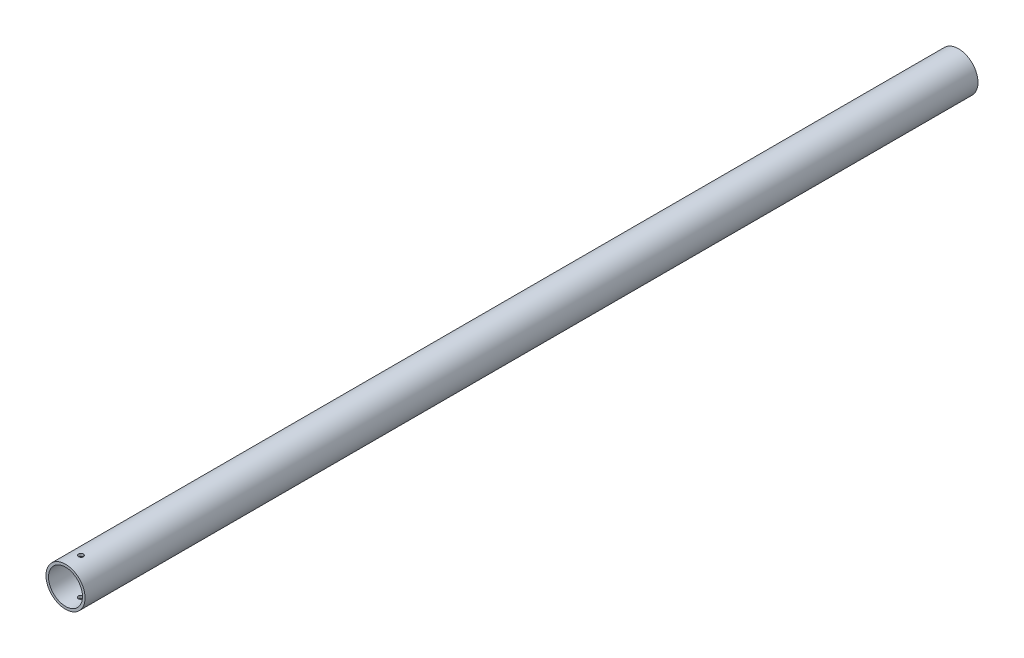
from build123d import *

# Parameters (mm, degrees)
SKETCH1_R               = 12.7
SKETCH1_R_2             = 11.049
BOSS_EXTRUDE1_DEPTH     = 580
SKETCH2_R               = 1.6
CUT_EXTRUDE1_DEPTH      = 13.7
CUT_EXTRUDE1_DEPTH_BACK = 13.7


with BuildPart() as part:
    # Sketch1 → Boss-Extrude1 (new body)
    with BuildSketch(Plane.XY):
        Circle(SKETCH1_R)
        Circle(SKETCH1_R_2, mode=Mode.SUBTRACT)
    extrude(amount=BOSS_EXTRUDE1_DEPTH)

    # Sketch2 → Cut-Extrude1 (cut, two sides)
    with BuildSketch(Plane(origin=(0, 0, 0), x_dir=(1, 0, 0), z_dir=(0, 1, 0))) as cut_extrude1_sk:
        with Locations((0, -570)):
            Circle(SKETCH2_R)
    extrude(amount=CUT_EXTRUDE1_DEPTH, mode=Mode.SUBTRACT)
    extrude(cut_extrude1_sk.sketch, amount=-CUT_EXTRUDE1_DEPTH_BACK, mode=Mode.SUBTRACT)


solid = part.part
